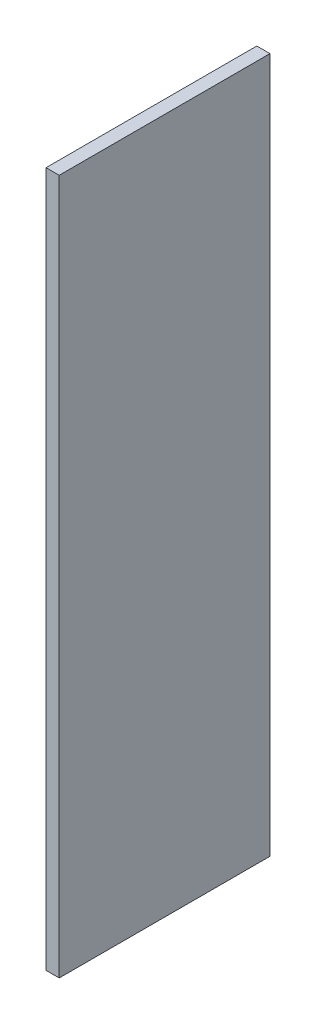
from build123d import *

# Parameters (mm, degrees)
SKETCH1_W           = 288
SKETCH1_H           = 950
BOSS_EXTRUDE1_DEPTH = 18


with BuildPart() as part:
    # Sketch1 → Boss-Extrude1 (new body)
    with BuildSketch(Plane(origin=(0, 0, 0), x_dir=(0, 0, -1), z_dir=(1, 0, 0))):
        with Locations((-123.607933189, -417.219556499)):
            Rectangle(SKETCH1_W, SKETCH1_H)
    extrude(amount=BOSS_EXTRUDE1_DEPTH)


solid = part.part
